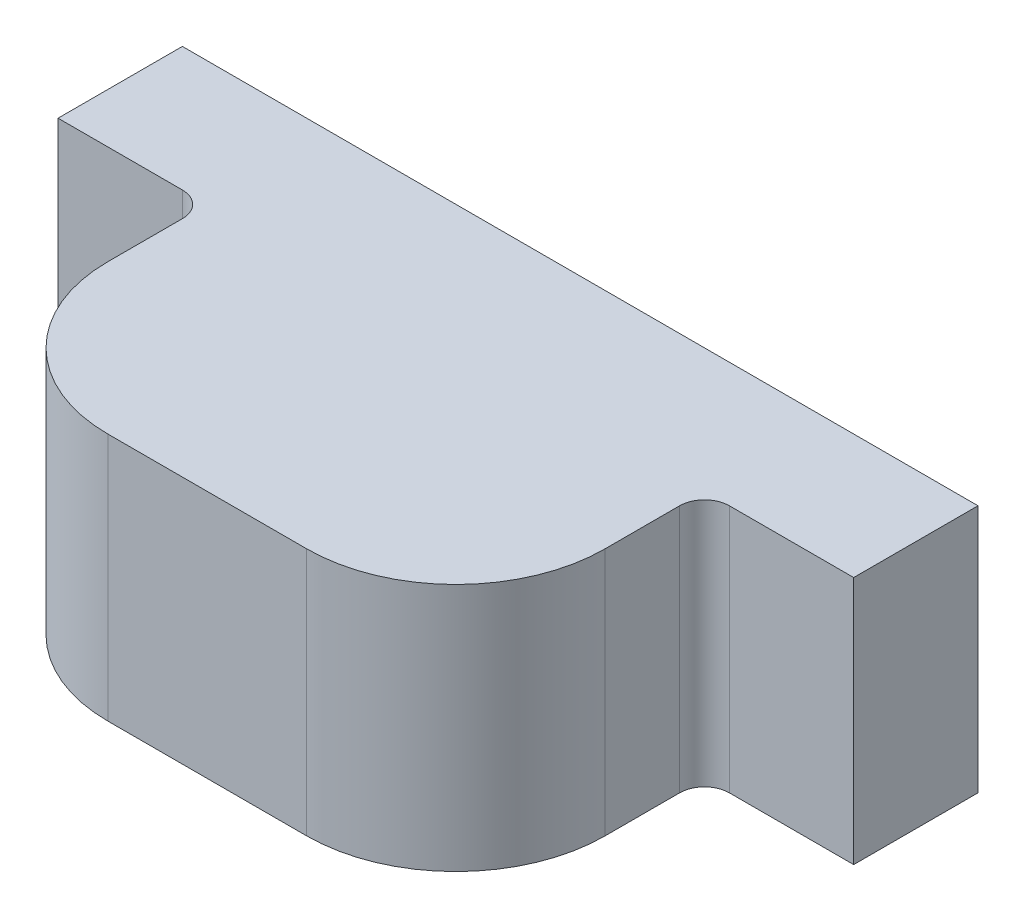
from build123d import *

# Parameters (mm, degrees)
BOSS_EXTRUDE1_DEPTH = 1


with BuildPart() as part:
    # Sketch1 → Boss-Extrude1 (new body)
    with BuildSketch(Plane(origin=(0, 0, 0), x_dir=(1, 0, 0), z_dir=(0, 1, 0))):
        with BuildLine():
            Line((-1.1, -0.25), (-1.6, -0.25))
            Line((-1.6, -0.25), (-1.6, 0.25))
            Line((-1.6, 0.25), (1.6, 0.25))
            Line((1.6, 0.25), (1.6, -0.25))
            Line((1.6, -0.25), (1.1, -0.25))
            ThreePointArc((1.1, -0.25), (1.029289322, -0.279289322), (1, -0.35))
            Line((1, -0.35), (1, -0.65))
            ThreePointArc((1, -0.65), (0.824264069, -1.074264069), (0.4, -1.25))
            Line((0.4, -1.25), (-0.4, -1.25))
            ThreePointArc((-0.4, -1.25), (-0.824264069, -1.074264069), (-1, -0.65))
            Line((-1, -0.65), (-1, -0.35))
            ThreePointArc((-1, -0.35), (-1.029289322, -0.279289322), (-1.1, -0.25))
        make_face()
    extrude(amount=BOSS_EXTRUDE1_DEPTH)


solid = part.part
